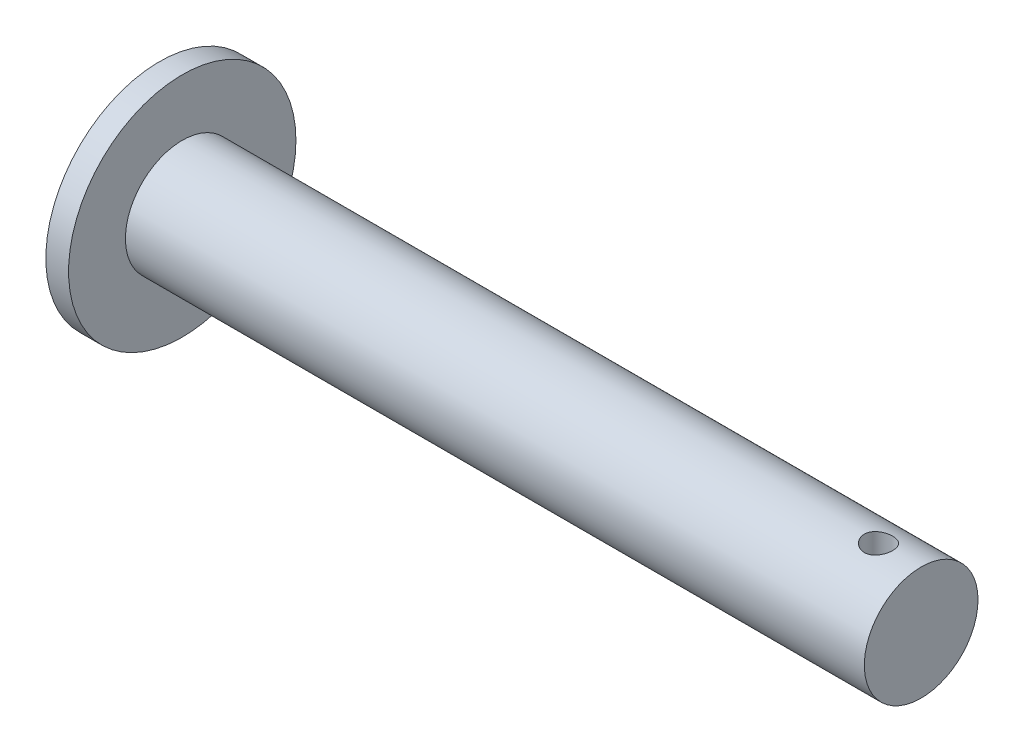
from build123d import *

# Parameters (mm, degrees)
SKETCH1_R           = 12.7
BOSS_EXTRUDE1_DEPTH = 2.54
SKETCH2_R           = 6.35
BOSS_EXTRUDE2_DEPTH = 82.55
SKETCH3_R           = 1.5875
CUT_EXTRUDE1_DEPTH  = 12.7


with BuildPart() as part:
    # Sketch1 → Boss-Extrude1 (new body)
    with BuildSketch(Plane(origin=(0, 0, 0), x_dir=(0, 0, -1), z_dir=(1, 0, 0))):
        Circle(SKETCH1_R)
    extrude(amount=BOSS_EXTRUDE1_DEPTH)

    # Sketch2 → Boss-Extrude2 (add)
    with BuildSketch(Plane(origin=(2.54, 0, 0), x_dir=(0, 0, -1), z_dir=(1, 0, 0))):
        Circle(SKETCH2_R)
    extrude(amount=BOSS_EXTRUDE2_DEPTH)

    # Sketch3 → Cut-Extrude1 (cut, symmetric)
    with BuildSketch(Plane(origin=(0, 0, 0), x_dir=(1, 0, 0), z_dir=(0, 1, 0))):
        with Locations((80.3275, 0)):
            Circle(SKETCH3_R)
    extrude(amount=CUT_EXTRUDE1_DEPTH, both=True, mode=Mode.SUBTRACT)


solid = part.part
